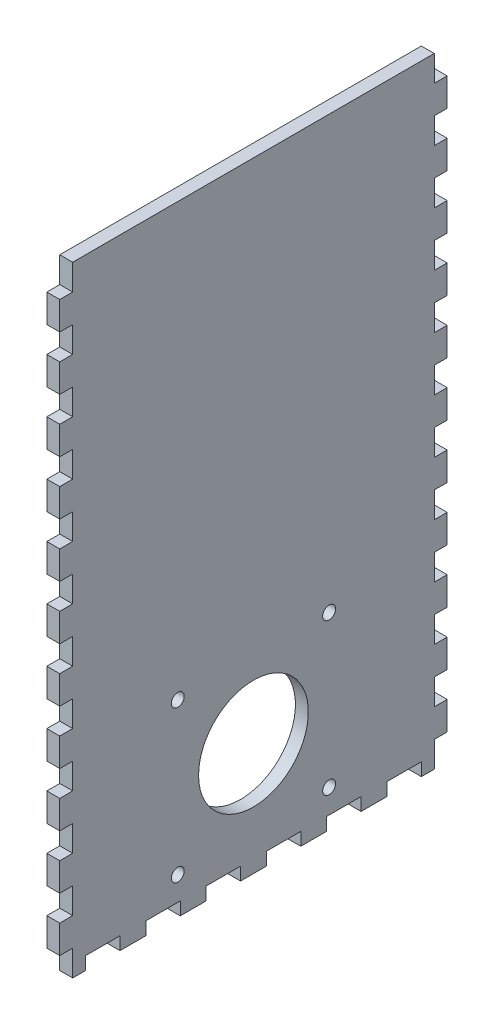
from build123d import *

# Parameters (mm, degrees)
SKETCH1_W           = 508
SKETCH1_H           = 190.5
BOSS_EXTRUDE1_DEPTH = 6.35
SKETCH2_W           = 508
SKETCH2_H           = 190.5
SKETCH2_W_2         = 495.3
SKETCH2_H_2         = 177.8
BOSS_EXTRUDE2_DEPTH = 298.45
SKETCH3_W           = 6.35
SKETCH3_H           = 16.933333333
SKETCH3_H_2         = 16.933333334
CUT_EXTRUDE1_DEPTH  = 12.7
SKETCH4_W           = 6.35
SKETCH4_H           = 15.875
CUT_EXTRUDE2_DEPTH  = 6.35
SKETCH6_W           = 514.801062296
SKETCH6_H           = 254.881465808
CUT_EXTRUDE5_DEPTH  = 305.8
SKETCH5_W           = 6.35
SKETCH5_H           = 16.933333333
SKETCH5_H_2         = 16.933333334
CUT_EXTRUDE6_DEPTH  = 6.35
SKETCH7_W           = 6.35
SKETCH7_H           = 12.7
CUT_EXTRUDE7_DEPTH  = 7.35
SKETCH8_R           = 26.9875
SKETCH8_R_2         = 3.175
CUT_EXTRUDE8_DEPTH  = 7.35


with BuildPart() as part:
    # Sketch1 → Boss-Extrude1 (new body)
    with BuildSketch(Plane(origin=(0, 0, 0), x_dir=(1, 0, 0), z_dir=(0, 1, 0))):
        Rectangle(SKETCH1_W, SKETCH1_H)
    extrude(amount=BOSS_EXTRUDE1_DEPTH)

    # Sketch2 → Boss-Extrude2 (add)
    with BuildSketch(Plane(origin=(0, 6.35, 0), x_dir=(1, 0, 0), z_dir=(0, 1, 0))):
        Rectangle(SKETCH2_W, SKETCH2_H)
        Rectangle(SKETCH2_W_2, SKETCH2_H_2, mode=Mode.SUBTRACT)
    extrude(amount=BOSS_EXTRUDE2_DEPTH)

    # Sketch3 → Cut-Extrude1 (cut)
    with BuildSketch(Plane.XY.offset(95.25)):
        with BuildLine():
            Line((-3.302, 283.21), (-3.302, 6.35))
            Line((-3.302, 6.35), (3.302, 6.35))
            Line((3.302, 6.35), (3.302, 292.354))
            Line((3.302, 292.354), (-16.256, 292.354))
            Line((-16.256, 292.354), (-16.256, 285.75))
            Line((-16.256, 285.75), (-5.842, 285.75))
            ThreePointArc((-5.842, 285.75), (-4.045948776, 285.006051224), (-3.302, 283.21))
        make_face()
        with Locations((12.827, 80.433333334)):
            Rectangle(SKETCH3_W, SKETCH3_H)
        with Locations((12.827, 50.8)):
            Rectangle(SKETCH3_W, SKETCH3_H_2)
        with Locations((12.827, 21.166666667)):
            Rectangle(SKETCH3_W, SKETCH3_H)
    extrude(amount=-CUT_EXTRUDE1_DEPTH, mode=Mode.SUBTRACT)

    # Sketch4 → Cut-Extrude2 (cut)
    with BuildSketch(Plane.XY.offset(-88.9)):
        with Locations((-19.431, 284.1625)):
            Rectangle(SKETCH4_W, SKETCH4_H)
        with Locations((-19.431, 255.5875)):
            Rectangle(SKETCH4_W, SKETCH4_H)
        with Locations((-19.431, 227.0125)):
            Rectangle(SKETCH4_W, SKETCH4_H)
        with Locations((-19.431, 198.4375)):
            Rectangle(SKETCH4_W, SKETCH4_H)
        with Locations((-19.431, 169.8625)):
            Rectangle(SKETCH4_W, SKETCH4_H)
        with Locations((-19.431, 141.2875)):
            Rectangle(SKETCH4_W, SKETCH4_H)
        with Locations((-19.431, 112.7125)):
            Rectangle(SKETCH4_W, SKETCH4_H)
        with Locations((-19.431, 84.1375)):
            Rectangle(SKETCH4_W, SKETCH4_H)
        with Locations((-19.431, 55.5625)):
            Rectangle(SKETCH4_W, SKETCH4_H)
        with Locations((-19.431, 26.9875)):
            Rectangle(SKETCH4_W, SKETCH4_H)
    cut_extrude2 = extrude(amount=-CUT_EXTRUDE2_DEPTH, mode=Mode.SUBTRACT)

    # Mirror1: Cut-Extrude2 across plane
    add(cut_extrude2.mirror(Plane.ZY.offset(6.477)), mode=Mode.SUBTRACT)

    # Sketch6 → Cut-Extrude5 (cut, through all)
    with BuildSketch(Plane(origin=(0, 0, 0), x_dir=(1, 0, 0), z_dir=(0, 1, 0))):
        with Locations((9.750531148, -10.000845247)):
            Rectangle(SKETCH6_W, SKETCH6_H)
    extrude(amount=CUT_EXTRUDE5_DEPTH, mode=Mode.SUBTRACT)

    # Sketch5 → Cut-Extrude6 (cut)
    with BuildSketch(Plane(origin=(0, 0, 0), x_dir=(-1, 0, 0), z_dir=(0, -1, 0))):
        with Locations((250.825, -74.083333334)):
            Rectangle(SKETCH5_W, SKETCH5_H)
        with Locations((250.825, -44.45)):
            Rectangle(SKETCH5_W, SKETCH5_H_2)
        with Locations((250.825, -14.816666667)):
            Rectangle(SKETCH5_W, SKETCH5_H)
        with Locations((250.825, 14.816666667)):
            Rectangle(SKETCH5_W, SKETCH5_H)
        with Locations((250.825, 44.45)):
            Rectangle(SKETCH5_W, SKETCH5_H_2)
        with Locations((250.825, 74.083333334)):
            Rectangle(SKETCH5_W, SKETCH5_H)
    extrude(amount=-CUT_EXTRUDE6_DEPTH, mode=Mode.SUBTRACT)

    # Sketch7 → Cut-Extrude7 (cut, through all)
    with BuildSketch(Plane.ZY.offset(254)):
        with Locations((-92.075, 32.904545455)):
            Rectangle(SKETCH7_W, SKETCH7_H)
        with Locations((-92.075, 6.35)):
            Rectangle(SKETCH7_W, SKETCH7_H)
        with Locations((-92.075, 59.459090909)):
            Rectangle(SKETCH7_W, SKETCH7_H)
        with Locations((-92.075, 86.013636364)):
            Rectangle(SKETCH7_W, SKETCH7_H)
        with Locations((-92.075, 112.568181818)):
            Rectangle(SKETCH7_W, SKETCH7_H)
        with Locations((-92.075, 139.122727273)):
            Rectangle(SKETCH7_W, SKETCH7_H)
        with Locations((-92.075, 165.677272727)):
            Rectangle(SKETCH7_W, SKETCH7_H)
        with Locations((-92.075, 192.231818182)):
            Rectangle(SKETCH7_W, SKETCH7_H)
        with Locations((-92.075, 218.786363636)):
            Rectangle(SKETCH7_W, SKETCH7_H)
        with Locations((-92.075, 245.340909091)):
            Rectangle(SKETCH7_W, SKETCH7_H)
        with Locations((-92.075, 271.895454545)):
            Rectangle(SKETCH7_W, SKETCH7_H)
        with Locations((-92.075, 298.45)):
            Rectangle(SKETCH7_W, SKETCH7_H)
        with Locations((92.075, 298.45)):
            Rectangle(SKETCH7_W, SKETCH7_H)
        with Locations((92.075, 271.895454545)):
            Rectangle(SKETCH7_W, SKETCH7_H)
        with Locations((92.075, 245.340909091)):
            Rectangle(SKETCH7_W, SKETCH7_H)
        with Locations((92.075, 218.786363636)):
            Rectangle(SKETCH7_W, SKETCH7_H)
        with Locations((92.075, 192.231818182)):
            Rectangle(SKETCH7_W, SKETCH7_H)
        with Locations((92.075, 165.677272727)):
            Rectangle(SKETCH7_W, SKETCH7_H)
        with Locations((92.075, 139.122727273)):
            Rectangle(SKETCH7_W, SKETCH7_H)
        with Locations((92.075, 112.568181818)):
            Rectangle(SKETCH7_W, SKETCH7_H)
        with Locations((92.075, 86.013636364)):
            Rectangle(SKETCH7_W, SKETCH7_H)
        with Locations((92.075, 59.459090909)):
            Rectangle(SKETCH7_W, SKETCH7_H)
        with Locations((92.075, 32.904545455)):
            Rectangle(SKETCH7_W, SKETCH7_H)
        with Locations((92.075, 6.35)):
            Rectangle(SKETCH7_W, SKETCH7_H)
    extrude(amount=-CUT_EXTRUDE7_DEPTH, mode=Mode.SUBTRACT)

    # Sketch8 → Cut-Extrude8 (cut, through all)
    with BuildSketch(Plane.ZY.offset(254)):
        with Locations((0, 55.372)):
            Circle(SKETCH8_R)
        with Locations((-37.211, 92.583)):
            Circle(SKETCH8_R_2)
        with Locations((37.211, 92.583)):
            Circle(SKETCH8_R_2)
        with Locations((37.211, 18.161)):
            Circle(SKETCH8_R_2)
        with Locations((-37.211, 18.161)):
            Circle(SKETCH8_R_2)
    extrude(amount=-CUT_EXTRUDE8_DEPTH, mode=Mode.SUBTRACT)


solid = part.part
